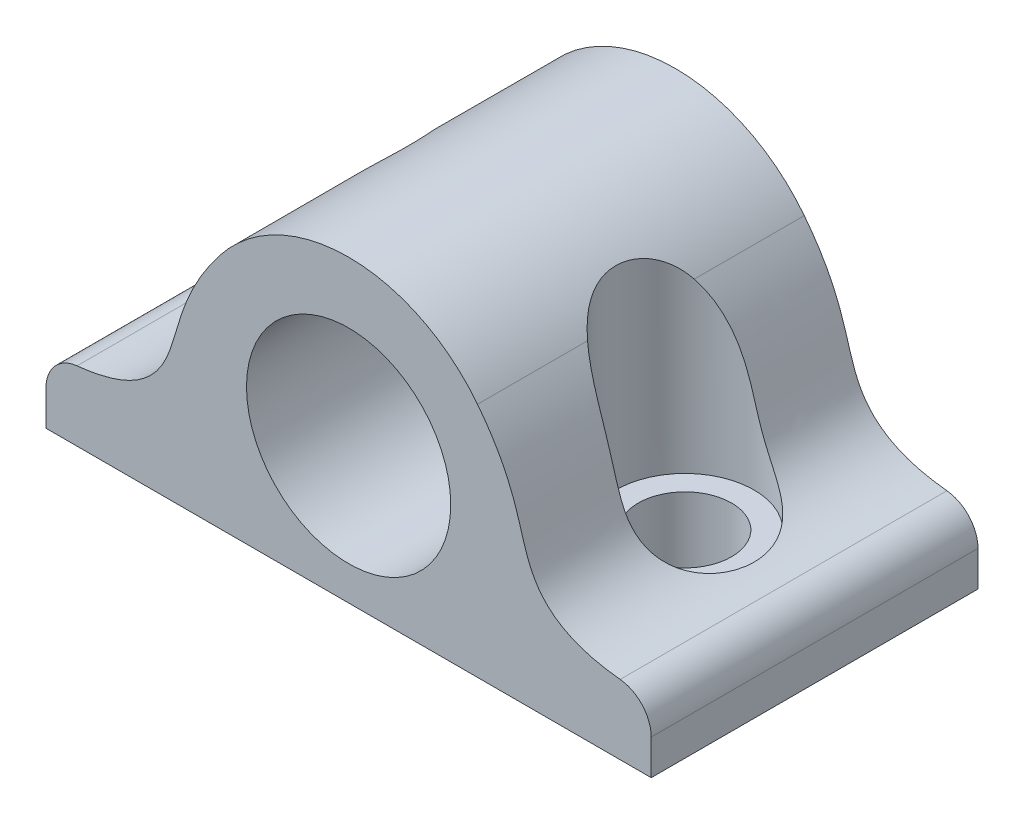
from build123d import *

# Parameters (mm, degrees)
SKETCH1_R           = 7.5
BOSS_EXTRUDE1_DEPTH = 12
SKETCH3_R           = 3.425
CUT_EXTRUDE1_DEPTH  = 23.0000001
FILLET1_R           = 2.54
SKETCH4_R           = 5.08
CUT_EXTRUDE2_DEPTH  = 18.000000194


with BuildPart() as part:
    # Sketch1 → Boss-Extrude1 (new body, symmetric)
    with BuildSketch(Plane.XY):
        with BuildLine():
            Line((22.225, -10), (-22.225, -10))
            Line((-22.225, -10), (-22.225, -5))
            add(Edge.make_bspline(
                [(-22.225, -5), (-16.631079064, -4.98201906), (-12.322747723, -1.728386223), (-12.530535341, 3.440374129), (-9.467504716, 7.373354356)],
                knots=[0, 0, 0, 0, 0.501954987, 1, 1, 1, 1], degree=3))
            ThreePointArc((-9.467504716, 7.373354356), (0, 12), (9.467504716, 7.373354356))
            add(Edge.make_bspline(
                [(22.225, -5), (16.631079064, -4.98201906), (12.322747723, -1.728386223), (12.530535341, 3.440374129), (9.467504716, 7.373354356)],
                knots=[0, 0, 0, 0, 0.501954987, 1, 1, 1, 1], degree=3))
            Line((22.225, -5), (22.225, -10))
        make_face()
        Circle(SKETCH1_R, mode=Mode.SUBTRACT)
    extrude(amount=BOSS_EXTRUDE1_DEPTH, both=True)

    # Sketch3 → Cut-Extrude1 (cut, through all)
    with BuildSketch(Plane.XZ.offset(10)):
        with Locations((-12.7, 0)):
            Circle(SKETCH3_R)
        with Locations((12.7, 0)):
            Circle(SKETCH3_R)
    extrude(amount=-CUT_EXTRUDE1_DEPTH, mode=Mode.SUBTRACT)

    # Fillet1
    fillet1_edges = [part.edges().sort_by_distance(p)[0] for p in [
        (22.225, -5, -6),
        (-22.225, -5, 6),
    ]]
    fillet(fillet1_edges, radius=FILLET1_R)

    # Sketch4 → Cut-Extrude2 (cut, through all)
    with BuildSketch(Plane(origin=(0, -5.000000094, 0), x_dir=(-1, 0, 0), z_dir=(0, -1, 0))):
        with Locations((12.7, 0)):
            Circle(SKETCH4_R)
        with Locations((-12.7, 0)):
            Circle(SKETCH4_R)
    extrude(amount=-CUT_EXTRUDE2_DEPTH, mode=Mode.SUBTRACT)


solid = part.part
